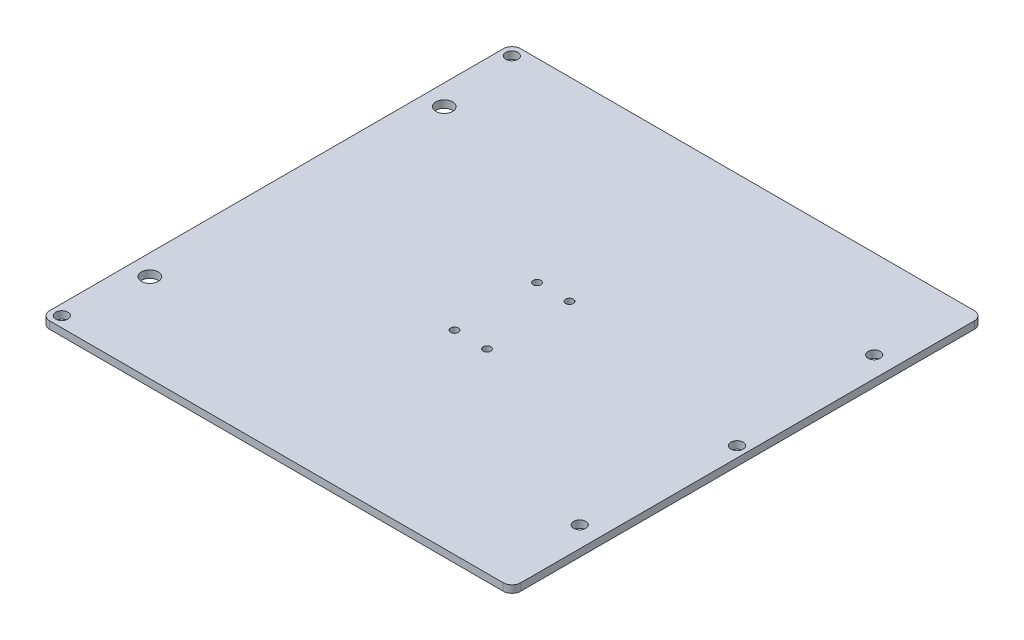
from build123d import *

# Parameters (mm, degrees)
SKETCH1_W               = 203.2
SKETCH1_H               = 203.2
BOSS_EXTRUDE1_DEPTH     = 3.175
WHEEL_HOLES_REACH       = 5.175
SKETCH2_R               = 3.6
SKETCH2_R_2             = 2.625
BUILD_PLATE_HOLES_REACH = 5.175
SKETCH3_R               = 2.625
FILLET1_R               = 3.81
BELT_CLAMP_HOLES_REACH  = 5.175
SKETCH4_R               = 1.65


with BuildPart() as part:
    # Sketch1 → Boss-Extrude1 (new body)
    with BuildSketch(Plane(origin=(0, 0, 0), x_dir=(1, 0, 0), z_dir=(0, 1, 0))):
        with Locations((101.6, 101.6)):
            Rectangle(SKETCH1_W, SKETCH1_H)
    extrude(amount=BOSS_EXTRUDE1_DEPTH)

    # Sketch2 → wheel holes (cut, up to next)
    with BuildSketch(Plane(origin=(0, 3.175, 0), x_dir=(1, 0, 0), z_dir=(0, 1, 0)), mode=Mode.PRIVATE) as wheel_holes_sk1:
        with Locations((8.90143, 38.1)):
            Circle(SKETCH2_R)
    wheel_holes_tool1 = extrude(wheel_holes_sk1.sketch, amount=-WHEEL_HOLES_REACH, mode=Mode.PRIVATE) & part.part
    add(wheel_holes_tool1.solids().sort_by_distance((8.90143, 3.175, -38.1))[0], mode=Mode.SUBTRACT)
    # Sketch2 → wheel holes (cut, up to next)
    with BuildSketch(Plane(origin=(0, 3.175, 0), x_dir=(1, 0, 0), z_dir=(0, 1, 0)), mode=Mode.PRIVATE) as wheel_holes_sk2:
        with Locations((8.90143, 165.1)):
            Circle(SKETCH2_R)
    wheel_holes_tool2 = extrude(wheel_holes_sk2.sketch, amount=-WHEEL_HOLES_REACH, mode=Mode.PRIVATE) & part.part
    add(wheel_holes_tool2.solids().sort_by_distance((8.90143, 3.175, -165.1))[0], mode=Mode.SUBTRACT)
    # Sketch2 → wheel holes (cut, up to next)
    with BuildSketch(Plane(origin=(0, 3.175, 0), x_dir=(1, 0, 0), z_dir=(0, 1, 0)), mode=Mode.PRIVATE) as wheel_holes_sk3:
        with Locations((194.29857, 38.1)):
            Circle(SKETCH2_R_2)
    wheel_holes_tool3 = extrude(wheel_holes_sk3.sketch, amount=-WHEEL_HOLES_REACH, mode=Mode.PRIVATE) & part.part
    add(wheel_holes_tool3.solids().sort_by_distance((194.29857, 3.175, -38.1))[0], mode=Mode.SUBTRACT)
    # Sketch2 → wheel holes (cut, up to next)
    with BuildSketch(Plane(origin=(0, 3.175, 0), x_dir=(1, 0, 0), z_dir=(0, 1, 0)), mode=Mode.PRIVATE) as wheel_holes_sk4:
        with Locations((194.29857, 165.1)):
            Circle(SKETCH2_R_2)
    wheel_holes_tool4 = extrude(wheel_holes_sk4.sketch, amount=-WHEEL_HOLES_REACH, mode=Mode.PRIVATE) & part.part
    add(wheel_holes_tool4.solids().sort_by_distance((194.29857, 3.175, -165.1))[0], mode=Mode.SUBTRACT)

    # Sketch3 → build plate holes (cut, up to next)
    with BuildSketch(Plane.XZ, mode=Mode.PRIVATE) as build_plate_holes_sk1:
        with Locations((4.50088, -4.572)):
            Circle(SKETCH3_R)
    build_plate_holes_tool1 = extrude(build_plate_holes_sk1.sketch, amount=-BUILD_PLATE_HOLES_REACH, mode=Mode.PRIVATE) & part.part
    add(build_plate_holes_tool1.solids().sort_by_distance((4.50088, 0, -4.572))[0], mode=Mode.SUBTRACT)
    # Sketch3 → build plate holes (cut, up to next)
    with BuildSketch(Plane.XZ, mode=Mode.PRIVATE) as build_plate_holes_sk2:
        with Locations((4.50088, -198.628)):
            Circle(SKETCH3_R)
    build_plate_holes_tool2 = extrude(build_plate_holes_sk2.sketch, amount=-BUILD_PLATE_HOLES_REACH, mode=Mode.PRIVATE) & part.part
    add(build_plate_holes_tool2.solids().sort_by_distance((4.50088, 0, -198.628))[0], mode=Mode.SUBTRACT)
    # Sketch3 → build plate holes (cut, up to next)
    with BuildSketch(Plane.XZ, mode=Mode.PRIVATE) as build_plate_holes_sk3:
        with Locations((198.628, -101.6)):
            Circle(SKETCH3_R)
    build_plate_holes_tool3 = extrude(build_plate_holes_sk3.sketch, amount=-BUILD_PLATE_HOLES_REACH, mode=Mode.PRIVATE) & part.part
    add(build_plate_holes_tool3.solids().sort_by_distance((198.628, 0, -101.6))[0], mode=Mode.SUBTRACT)

    # Fillet1
    fillet1_edges = [part.edges().sort_by_distance(p)[0] for p in [
        (0, 1.5875, -203.2),
        (203.2, 1.5875, -203.2),
        (203.2, 1.5875, 0),
        (0, 1.5875, 0),
    ]]
    fillet(fillet1_edges, radius=FILLET1_R)

    # Sketch4 → belt clamp holes (cut, up to next)
    with BuildSketch(Plane(origin=(0, 3.175, 0), x_dir=(1, 0, 0), z_dir=(0, 1, 0)), mode=Mode.PRIVATE) as belt_clamp_holes_sk1:
        with Locations((94.6, 119.38)):
            Circle(SKETCH4_R)
    belt_clamp_holes_tool1 = extrude(belt_clamp_holes_sk1.sketch, amount=-BELT_CLAMP_HOLES_REACH, mode=Mode.PRIVATE) & part.part
    add(belt_clamp_holes_tool1.solids().sort_by_distance((94.6, 3.175, -119.38))[0], mode=Mode.SUBTRACT)
    # Sketch4 → belt clamp holes (cut, up to next)
    with BuildSketch(Plane(origin=(0, 3.175, 0), x_dir=(1, 0, 0), z_dir=(0, 1, 0)), mode=Mode.PRIVATE) as belt_clamp_holes_sk2:
        with Locations((108.6, 119.38)):
            Circle(SKETCH4_R)
    belt_clamp_holes_tool2 = extrude(belt_clamp_holes_sk2.sketch, amount=-BELT_CLAMP_HOLES_REACH, mode=Mode.PRIVATE) & part.part
    add(belt_clamp_holes_tool2.solids().sort_by_distance((108.6, 3.175, -119.38))[0], mode=Mode.SUBTRACT)
    # Sketch4 → belt clamp holes (cut, up to next)
    with BuildSketch(Plane(origin=(0, 3.175, 0), x_dir=(1, 0, 0), z_dir=(0, 1, 0)), mode=Mode.PRIVATE) as belt_clamp_holes_sk3:
        with Locations((108.6, 83.82)):
            Circle(SKETCH4_R)
    belt_clamp_holes_tool3 = extrude(belt_clamp_holes_sk3.sketch, amount=-BELT_CLAMP_HOLES_REACH, mode=Mode.PRIVATE) & part.part
    add(belt_clamp_holes_tool3.solids().sort_by_distance((108.6, 3.175, -83.82))[0], mode=Mode.SUBTRACT)
    # Sketch4 → belt clamp holes (cut, up to next)
    with BuildSketch(Plane(origin=(0, 3.175, 0), x_dir=(1, 0, 0), z_dir=(0, 1, 0)), mode=Mode.PRIVATE) as belt_clamp_holes_sk4:
        with Locations((94.6, 83.82)):
            Circle(SKETCH4_R)
    belt_clamp_holes_tool4 = extrude(belt_clamp_holes_sk4.sketch, amount=-BELT_CLAMP_HOLES_REACH, mode=Mode.PRIVATE) & part.part
    add(belt_clamp_holes_tool4.solids().sort_by_distance((94.6, 3.175, -83.82))[0], mode=Mode.SUBTRACT)


solid = part.part
